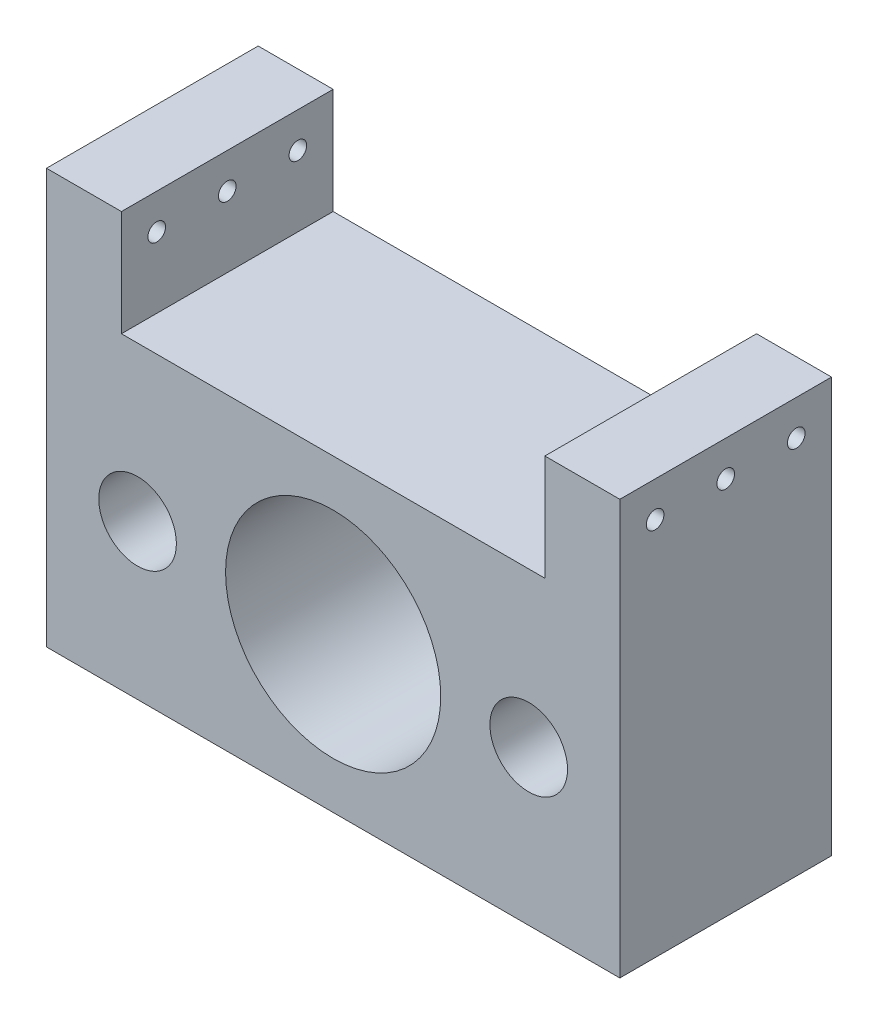
from build123d import *

# Parameters (mm, degrees)
SKETCH1_R               = 4.4
SKETCH1_R_2             = 12.196440552
BOSS_EXTRUDE1_DEPTH     = 24
SKETCH1_3_R             = 12.196440552
SKETCH1_3_R_2           = 1.5
SKETCH1_3_R_3           = 5
BOSS_EXTRUDE2_DEPTH     = 5
CUT_EXTRUDE1_DEPTH      = 51.024993753
CUT_EXTRUDE1_DEPTH_BACK = 51.024993753
SKETCH2_R               = 1


with BuildPart() as part:
    # Sketch1 → Boss-Extrude1 (new body)
    with BuildSketch(Plane.XY):
        Polygon((-32.5, 29.5), (-32.5, -17.5), (32.5, -17.5), (32.5, 29.5), (24, 29.5), (24, 17.5), (-24, 17.5), (-24, 29.5), align=None)
        with Locations((22.171280209, 0)):
            Circle(SKETCH1_R, mode=Mode.SUBTRACT)
        with Locations((-22.171280209, 0)):
            Circle(SKETCH1_R, mode=Mode.SUBTRACT)
        Circle(SKETCH1_R_2, mode=Mode.SUBTRACT)
    extrude(amount=BOSS_EXTRUDE1_DEPTH)

    # Sketch1_3 → Boss-Extrude2 (add)
    with BuildSketch(Plane.XY):
        Circle(SKETCH1_3_R)
        with Locations((0, -8)):
            Circle(SKETCH1_3_R_2, mode=Mode.SUBTRACT)
        with Locations((-8, 0)):
            Circle(SKETCH1_3_R_2, mode=Mode.SUBTRACT)
        Circle(SKETCH1_3_R_3, mode=Mode.SUBTRACT)
        with Locations((8, 0)):
            Circle(SKETCH1_3_R_2, mode=Mode.SUBTRACT)
        with Locations((0, 8)):
            Circle(SKETCH1_3_R_2, mode=Mode.SUBTRACT)
    extrude(amount=BOSS_EXTRUDE2_DEPTH)

    # Sketch2 → Cut-Extrude1 (cut, two sides: drawn at the far end of the back side and taken through both)
    with BuildSketch(Plane(origin=(0, 0, 0), x_dir=(0, 0, -1), z_dir=(1, 0, 0)).offset(-CUT_EXTRUDE1_DEPTH_BACK)):
        with Locations((-20, 25.5)):
            Circle(SKETCH2_R)
        with Locations((-12, 25.5)):
            Circle(SKETCH2_R)
        with Locations((-4, 25.5)):
            Circle(SKETCH2_R)
    extrude(amount=CUT_EXTRUDE1_DEPTH + CUT_EXTRUDE1_DEPTH_BACK, mode=Mode.SUBTRACT)


solid = part.part
